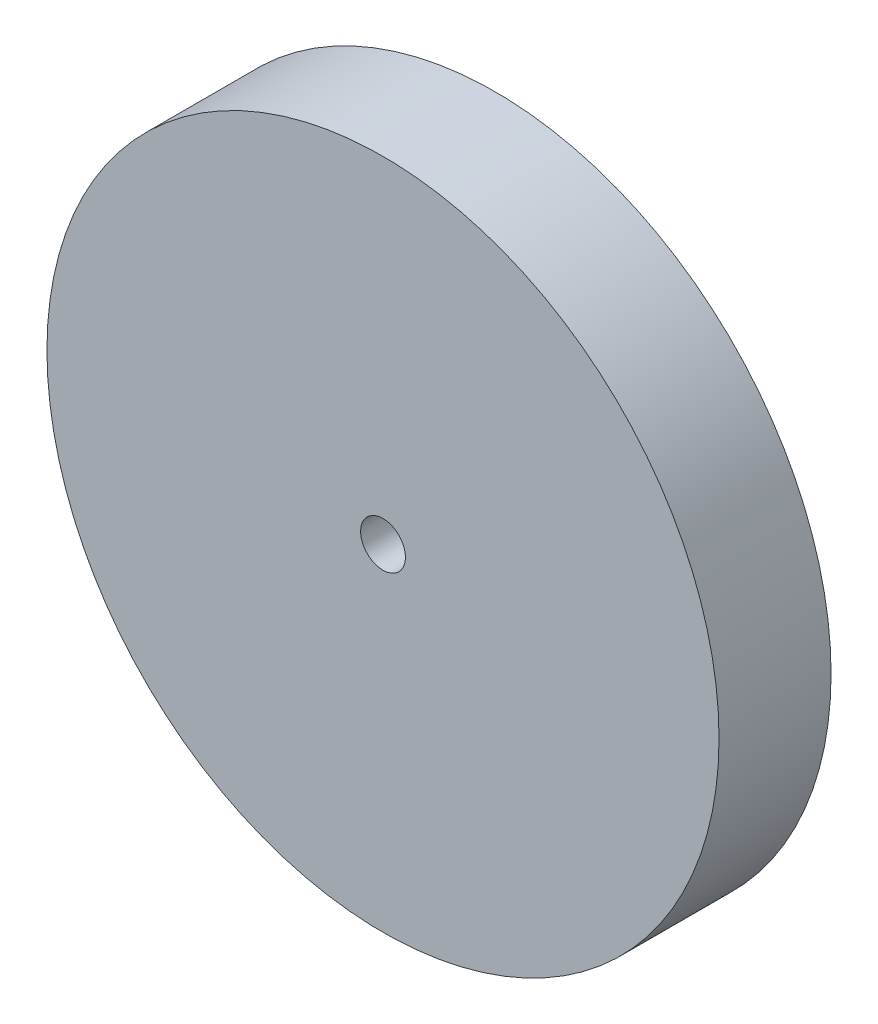
from build123d import *

# Parameters (mm, degrees)
IZIM1_R                     = 60
IZIM1_R_2                   = 4
Y_KSEKLIK_EKSTR_ZYON1_DEPTH = 20


with BuildPart() as part:
    # Çizim1 → Yükseklik-Ekstrüzyon1 (new body)
    with BuildSketch(Plane.XY):
        Circle(IZIM1_R)
        Circle(IZIM1_R_2, mode=Mode.SUBTRACT)
    extrude(amount=Y_KSEKLIK_EKSTR_ZYON1_DEPTH)


solid = part.part
